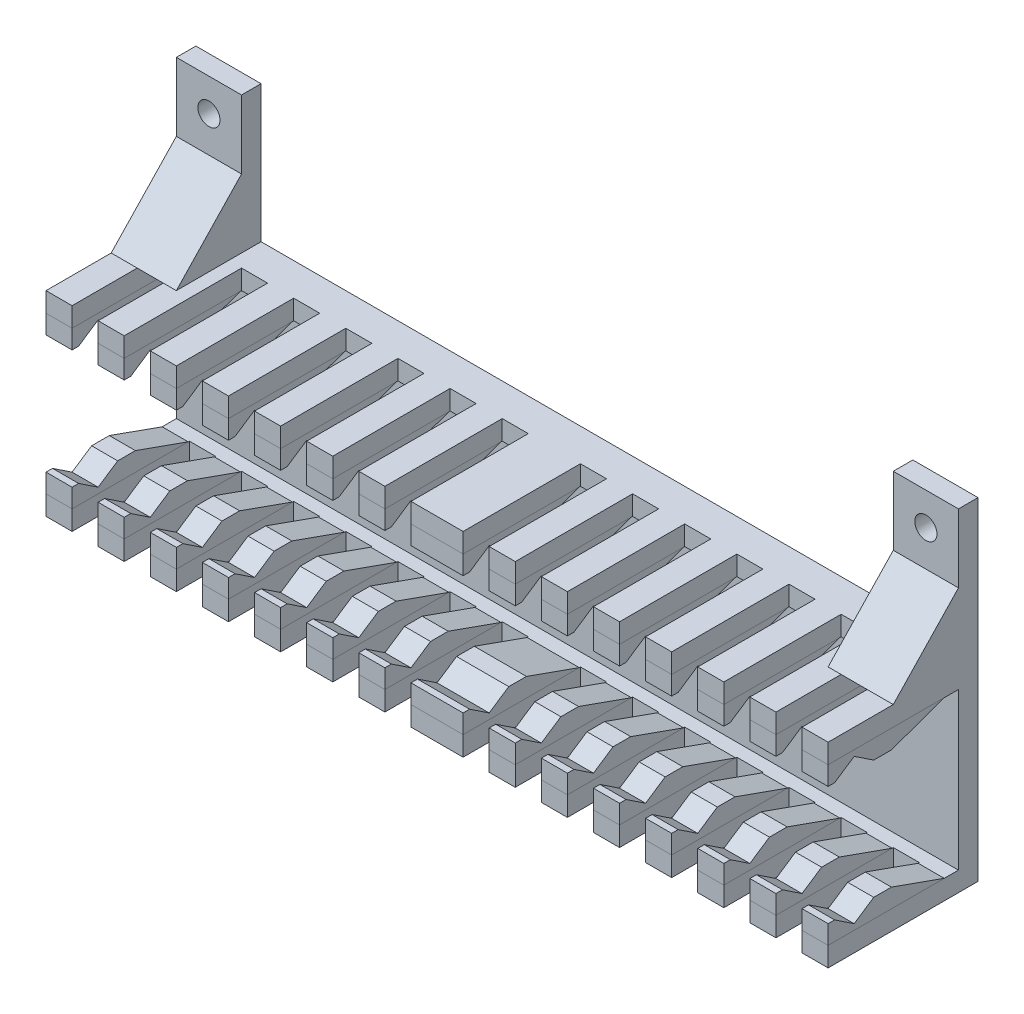
from build123d import *

# Parameters (mm, degrees)
ESQUISSE1_R             = 1.7
BOSS_EXTRU_1_DEPTH      = 3
ESQUISSE2_W             = 120
ESQUISSE2_H             = 3
BOSS_EXTRU_2_DEPTH      = 20
BOSS_EXTRU_3_DEPTH      = 120
BOSS_EXTRU_3_2_DEPTH    = 120
ENL_V_MAT_EXTRU_1_DEPTH = 120
ESQUISSE7_W             = 4
ESQUISSE7_H             = 18
ENL_V_MAT_EXTRU_2_DEPTH = 34
BOSS_EXTRU_4_DEPTH      = 10
BOSS_EXTRU_5_DEPTH      = 10


with BuildPart() as part:
    # Esquisse1 → Boss.-Extru.1 (new body)
    with BuildSketch(Plane.XY):
        Polygon((0, 0), (0, 51), (10, 51), (10, 30), (110, 30), (110, 51), (120, 51), (120, 0), align=None)
        with Locations((5, 46)):
            Circle(ESQUISSE1_R, mode=Mode.SUBTRACT)
        with Locations((115, 46)):
            Circle(ESQUISSE1_R, mode=Mode.SUBTRACT)
    extrude(amount=BOSS_EXTRU_1_DEPTH)

    # Esquisse2 → Boss.-Extru.2 (add)
    with BuildSketch(Plane.XY.offset(3)):
        with Locations((60, 1.5)):
            Rectangle(ESQUISSE2_W, ESQUISSE2_H)
        with Locations((60, 28.5)):
            Rectangle(ESQUISSE2_W, ESQUISSE2_H)
    extrude(amount=BOSS_EXTRU_2_DEPTH)


with BuildPart() as body_2:
    # Esquisse5 → Boss.-Extru.3 (new body)
    with BuildSketch(Plane(origin=(120, 0, 0), x_dir=(0, 0, -1), z_dir=(1, 0, 0))):
        Polygon((-23, 3), (-23, 5.884009081), (-13.285087081, 5.884009081), (-5.178494066, 3), align=None)
    extrude(amount=-BOSS_EXTRU_3_DEPTH)


with BuildPart() as body_3:
    # Esquisse5 → Boss.-Extru.3 2 (new body)
    with BuildSketch(Plane(origin=(120, 0, 0), x_dir=(0, 0, -1), z_dir=(1, 0, 0))):
        Polygon((-23, 27), (-5.178494066, 27), (-13.285087081, 24.115990919), (-23, 24.115990919), align=None)
    extrude(amount=-BOSS_EXTRU_3_2_DEPTH)


with BuildPart() as enl_v_mat_extru_1_tool:
    # Esquisse6 → Enlèv. mat.-Extru.1 (new body)
    with BuildSketch(Plane(origin=(120, 0, 0), x_dir=(0, 0, -1), z_dir=(1, 0, 0))):
        Polygon((-19, 3.884009081), (-16, 5.884009081), (-22, 5.884009081), align=None)
        Polygon((-22, 24.115990919), (-19, 26.115990919), (-16, 24.115990919), align=None)
    extrude(amount=-ENL_V_MAT_EXTRU_1_DEPTH)


with BuildPart() as body_2_1:
    add(body_2.part)

    # Enlèv. mat.-Extru.1: cut by enl_v_mat_extru_1_tool
    add(enl_v_mat_extru_1_tool.part, mode=Mode.SUBTRACT)


with BuildPart() as body_3_1:
    add(body_3.part)

    # Enlèv. mat.-Extru.1: cut by enl_v_mat_extru_1_tool
    add(enl_v_mat_extru_1_tool.part, mode=Mode.SUBTRACT)


with BuildPart() as enl_v_mat_extru_2_tool:
    # Esquisse7 → Enlèv. mat.-Extru.2 (new body)
    with BuildSketch(Plane.XZ):
        with Locations((54, 14)):
            Rectangle(ESQUISSE7_W, ESQUISSE7_H)
        with Locations((46, 14)):
            Rectangle(ESQUISSE7_W, ESQUISSE7_H)
        with Locations((38, 14)):
            Rectangle(ESQUISSE7_W, ESQUISSE7_H)
        with Locations((30, 14)):
            Rectangle(ESQUISSE7_W, ESQUISSE7_H)
        with Locations((22, 14)):
            Rectangle(ESQUISSE7_W, ESQUISSE7_H)
        with Locations((14, 14)):
            Rectangle(ESQUISSE7_W, ESQUISSE7_H)
        with Locations((6, 14)):
            Rectangle(ESQUISSE7_W, ESQUISSE7_H)
        with Locations((114, 14)):
            Rectangle(ESQUISSE7_W, ESQUISSE7_H)
        with Locations((106, 14)):
            Rectangle(ESQUISSE7_W, ESQUISSE7_H)
        with Locations((98, 14)):
            Rectangle(ESQUISSE7_W, ESQUISSE7_H)
        with Locations((90, 14)):
            Rectangle(ESQUISSE7_W, ESQUISSE7_H)
        with Locations((82, 14)):
            Rectangle(ESQUISSE7_W, ESQUISSE7_H)
        with Locations((74, 14)):
            Rectangle(ESQUISSE7_W, ESQUISSE7_H)
        with Locations((66, 14)):
            Rectangle(ESQUISSE7_W, ESQUISSE7_H)
    extrude(amount=-ENL_V_MAT_EXTRU_2_DEPTH)


with BuildPart() as part_1:
    add(part.part)

    # Enlèv. mat.-Extru.2: cut by enl_v_mat_extru_2_tool
    add(enl_v_mat_extru_2_tool.part, mode=Mode.SUBTRACT)

    # Esquisse8 → Boss.-Extru.4 (add)
    with BuildSketch(Plane(origin=(120, 0, 0), x_dir=(0, 0, -1), z_dir=(1, 0, 0))):
        Polygon((-3, 30), (-13, 30), (-3, 40.5), align=None)
    extrude(amount=-BOSS_EXTRU_4_DEPTH)

    # Esquisse9 → Boss.-Extru.5 (add)
    with BuildSketch(Plane.ZY):
        Polygon((3, 40.5), (13, 30), (3, 30), align=None)
    extrude(amount=-BOSS_EXTRU_5_DEPTH)


with BuildPart() as body_2_2:
    add(body_2_1.part)

    # Enlèv. mat.-Extru.2: cut by enl_v_mat_extru_2_tool
    add(enl_v_mat_extru_2_tool.part, mode=Mode.SUBTRACT)


with BuildPart() as body_3_2:
    add(body_3_1.part)

    # Enlèv. mat.-Extru.2: cut by enl_v_mat_extru_2_tool
    add(enl_v_mat_extru_2_tool.part, mode=Mode.SUBTRACT)


solid = Compound([part_1.part, body_2_2.part, body_3_2.part])
